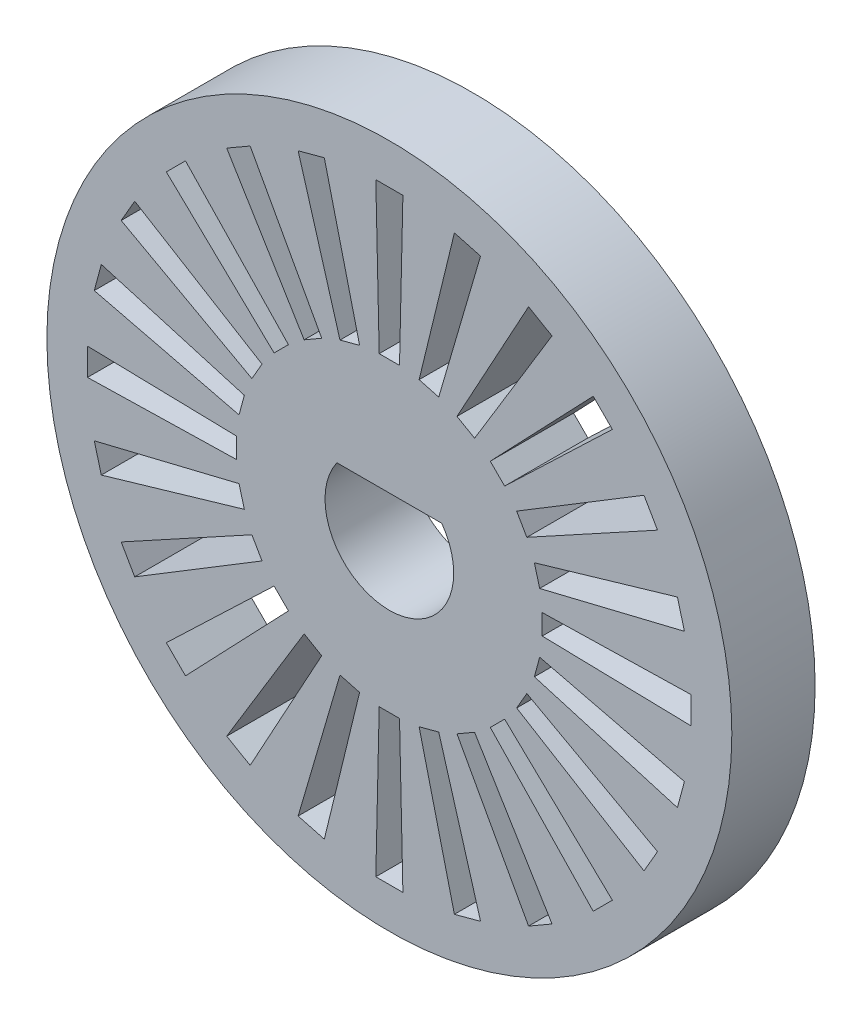
from build123d import *

# Parameters (mm, degrees)
CROQUIS1_R              = 12.84605
SALIENTE_EXTRUIR2_DEPTH = 3.1242


with BuildPart() as part:
    # Croquis1 → Saliente-Extruir2 (new body)
    with BuildSketch(Plane.XY):
        Circle(CROQUIS1_R)
        Polygon((0.508, 11.32205), (0.381, 5.73405), (-0.381, 5.73405), (-0.508, 11.32205), align=None, mode=Mode.SUBTRACT)
        Polygon((-7.646688087, -8.365108577), (-8.365108577, -7.646688087), (-4.323993322, -3.785177955), (-3.785177955, -4.323993322), align=None, mode=Mode.SUBTRACT)
        Polygon((-5.221084095, -10.059182923), (-6.100965905, -9.551182923), (-3.196980679, -4.775332967), (-2.537069321, -5.156332967), align=None, mode=Mode.SUBTRACT)
        Polygon((-2.43967185, -11.067740576), (-3.421052489, -10.804780427), (-1.852099085, -5.440056928), (-1.116063606, -5.63727704), align=None, mode=Mode.SUBTRACT)
        Polygon((-9.551182923, -6.100965905), (-10.059182923, -5.221084095), (-5.156332967, -2.537069321), (-4.775332967, -3.196980679), align=None, mode=Mode.SUBTRACT)
        Polygon((-11.32205, -0.508), (-11.32205, 0.508), (-5.73405, 0.381), (-5.73405, -0.381), align=None, mode=Mode.SUBTRACT)
        Polygon((-10.804780427, -3.421052489), (-11.067740576, -2.43967185), (-5.63727704, -1.116063606), (-5.440056928, -1.852099085), align=None, mode=Mode.SUBTRACT)
        Polygon((0.508, -11.32205), (-0.508, -11.32205), (-0.381, -5.73405), (0.381, -5.73405), align=None, mode=Mode.SUBTRACT)
        Polygon((3.421052489, -10.804780427), (2.43967185, -11.067740576), (1.116063606, -5.63727704), (1.852099085, -5.440056928), align=None, mode=Mode.SUBTRACT)
        Polygon((6.100965905, -9.551182923), (5.221084095, -10.059182923), (2.537069321, -5.156332967), (3.196980679, -4.775332967), align=None, mode=Mode.SUBTRACT)
        Polygon((8.365108577, -7.646688087), (7.646688087, -8.365108577), (3.785177955, -4.323993322), (4.323993322, -3.785177955), align=None, mode=Mode.SUBTRACT)
        Polygon((10.059182923, -5.221084095), (9.551182923, -6.100965905), (4.775332967, -3.196980679), (5.156332967, -2.537069321), align=None, mode=Mode.SUBTRACT)
        Polygon((11.067740576, -2.43967185), (10.804780427, -3.421052489), (5.440056928, -1.852099085), (5.63727704, -1.116063606), align=None, mode=Mode.SUBTRACT)
        Polygon((-11.067740576, 2.43967185), (-10.804780427, 3.421052489), (-5.440056928, 1.852099085), (-5.63727704, 1.116063606), align=None, mode=Mode.SUBTRACT)
        Polygon((-10.059182923, 5.221084095), (-9.551182923, 6.100965905), (-4.775332967, 3.196980679), (-5.156332967, 2.537069321), align=None, mode=Mode.SUBTRACT)
        with BuildLine():
            Line((-1.96747554, 1.397), (1.96747554, 1.397))
            ThreePointArc((1.96747554, 1.397), (0, -2.413), (-1.96747554, 1.397))
        make_face(mode=Mode.SUBTRACT)
        Polygon((-8.365108577, 7.646688087), (-7.646688087, 8.365108577), (-3.785177955, 4.323993322), (-4.323993322, 3.785177955), align=None, mode=Mode.SUBTRACT)
        Polygon((-6.100965905, 9.551182923), (-5.221084095, 10.059182923), (-2.537069321, 5.156332967), (-3.196980679, 4.775332967), align=None, mode=Mode.SUBTRACT)
        Polygon((-3.421052489, 10.804780427), (-2.43967185, 11.067740576), (-1.116063606, 5.63727704), (-1.852099085, 5.440056928), align=None, mode=Mode.SUBTRACT)
        Polygon((10.804780427, 3.421052489), (11.067740576, 2.43967185), (5.63727704, 1.116063606), (5.440056928, 1.852099085), align=None, mode=Mode.SUBTRACT)
        Polygon((11.32205, 0.508), (11.32205, -0.508), (5.73405, -0.381), (5.73405, 0.381), align=None, mode=Mode.SUBTRACT)
        Polygon((9.551182923, 6.100965905), (10.059182923, 5.221084095), (5.156332967, 2.537069321), (4.775332967, 3.196980679), align=None, mode=Mode.SUBTRACT)
        Polygon((2.43967185, 11.067740576), (3.421052489, 10.804780427), (1.852099085, 5.440056928), (1.116063606, 5.63727704), align=None, mode=Mode.SUBTRACT)
        Polygon((5.221084095, 10.059182923), (6.100965905, 9.551182923), (3.196980679, 4.775332967), (2.537069321, 5.156332967), align=None, mode=Mode.SUBTRACT)
        Polygon((7.646688087, 8.365108577), (8.365108577, 7.646688087), (4.323993322, 3.785177955), (3.785177955, 4.323993322), align=None, mode=Mode.SUBTRACT)
    extrude(amount=SALIENTE_EXTRUIR2_DEPTH)


solid = part.part
